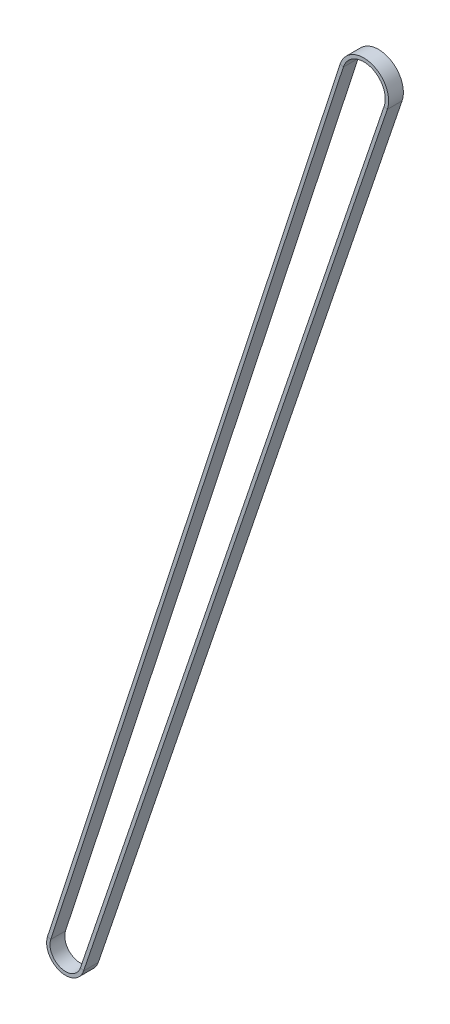
from build123d import *

# Parameters (mm, degrees)
SKETCH2_W = 1.38
SKETCH2_H = 6


with BuildPart() as part:
    # Sweep1: sweep along a path in Sketch1
    with BuildLine(Plane.XY) as sweep1_path:
        Line((6.01523436, -2.034565211), (129.672217689, 363.559877783))
        ThreePointArc((129.672217689, 363.559877783), (124.135446545, 374.669394664), (113.060574593, 369.063646606))
        Line((113.060574593, 369.063646606), (-6.040072344, 1.95959845))
        ThreePointArc((-6.040072344, 1.95959845), (-1.997120444, -6.027769897), (6.01523436, -2.034565211))
    # Sketch2 → Sweep1 (sweep)
    with BuildSketch(Plane(origin=(113.060574593, 369.063646606, 0), x_dir=(0.951192495, -0.308598181, 0), z_dir=(0.308598181, 0.951192495, 0))):
        with Locations((-0.69, 0)):
            Rectangle(SKETCH2_W, SKETCH2_H)
    sweep(path=sweep1_path.line)


solid = part.part
